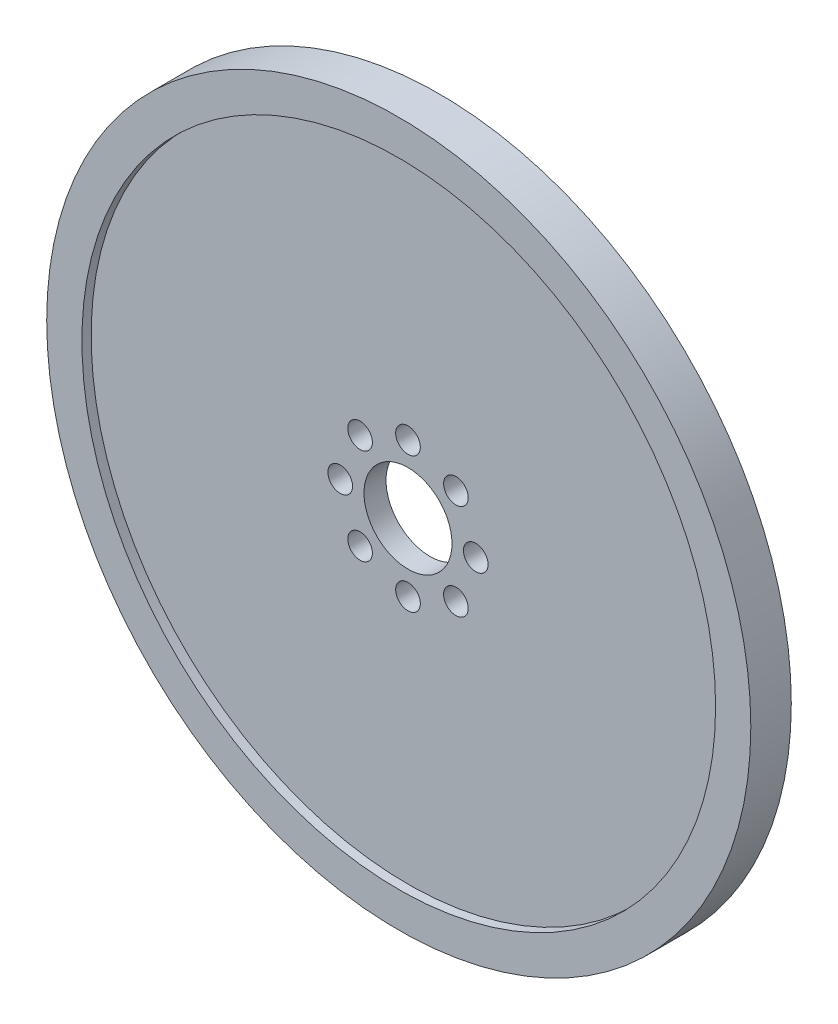
from build123d import *

# Parameters (mm, degrees)
SKETCH1_R           = 50.8
SKETCH1_R_2         = 45.72
BOSS_EXTRUDE1_DEPTH = 2.921
SKETCH3_R           = 45.72
SKETCH3_R_2         = 6.35
SKETCH3_R_3         = 1.778
BOSS_EXTRUDE2_DEPTH = 1.5875


with BuildPart() as part:
    # Sketch1 → Boss-Extrude1 (new body, symmetric)
    with BuildSketch(Plane.XY):
        Circle(SKETCH1_R)
        Circle(SKETCH1_R_2, mode=Mode.SUBTRACT)
    extrude(amount=BOSS_EXTRUDE1_DEPTH, both=True)

    # Sketch3 → Boss-Extrude2 (add, symmetric)
    with BuildSketch(Plane.XY):
        Circle(SKETCH3_R)
        Circle(SKETCH3_R_2, mode=Mode.SUBTRACT)
        with Locations((0, 9.779)):
            Circle(SKETCH3_R_3, mode=Mode.SUBTRACT)
        with Locations((6.914797213, 6.914797213)):
            Circle(SKETCH3_R_3, mode=Mode.SUBTRACT)
        with Locations((9.779, 0)):
            Circle(SKETCH3_R_3, mode=Mode.SUBTRACT)
        with Locations((6.914797213, -6.914797213)):
            Circle(SKETCH3_R_3, mode=Mode.SUBTRACT)
        with Locations((0, -9.779)):
            Circle(SKETCH3_R_3, mode=Mode.SUBTRACT)
        with Locations((-6.914797213, -6.914797213)):
            Circle(SKETCH3_R_3, mode=Mode.SUBTRACT)
        with Locations((-9.779, 0)):
            Circle(SKETCH3_R_3, mode=Mode.SUBTRACT)
        with Locations((-6.914797213, 6.914797213)):
            Circle(SKETCH3_R_3, mode=Mode.SUBTRACT)
    extrude(amount=BOSS_EXTRUDE2_DEPTH, both=True)


solid = part.part
